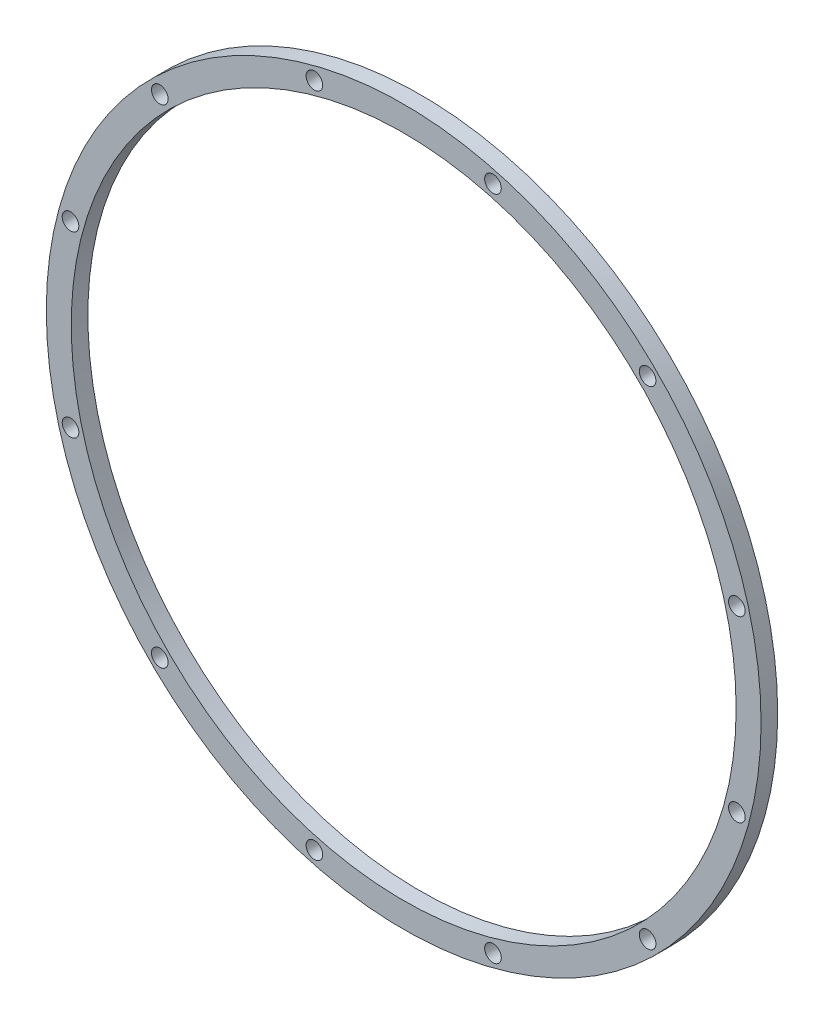
from build123d import *

# Parameters (mm, degrees)
FLANGESKETCH_R      = 546.101092202
FLANGESKETCH_R_2    = 508.001016002
FLANGEFEATURE_DEPTH = 25.4000508
SKETCH2_R           = 12.7
BOLT_HOLE_DEPTH     = 26.4000508
BOLTPATTERN_COUNT   = 12


with BuildPart() as part:
    # FlangeSketch → FlangeFeature (new body)
    with BuildSketch(Plane.XY):
        Circle(FLANGESKETCH_R)
        Circle(FLANGESKETCH_R_2, mode=Mode.SUBTRACT)
    extrude(amount=FLANGEFEATURE_DEPTH)

    # Sketch2 → Bolt Hole (cut, through all)
    with BuildSketch(Plane.XY.offset(25.4000508)):
        with Locations((-136.410860404, 509.092261732)):
            Circle(SKETCH2_R)
    bolt_hole = extrude(amount=-BOLT_HOLE_DEPTH, mode=Mode.SUBTRACT)

    # BoltPattern: Bolt Hole ×12 about axis
    boltpattern_axis = Axis((0, 0, 0), (0, 0, 1))
    for i in range(1, BOLTPATTERN_COUNT):
        add(bolt_hole.rotate(boltpattern_axis, i * 360 / BOLTPATTERN_COUNT), mode=Mode.SUBTRACT)


solid = part.part
